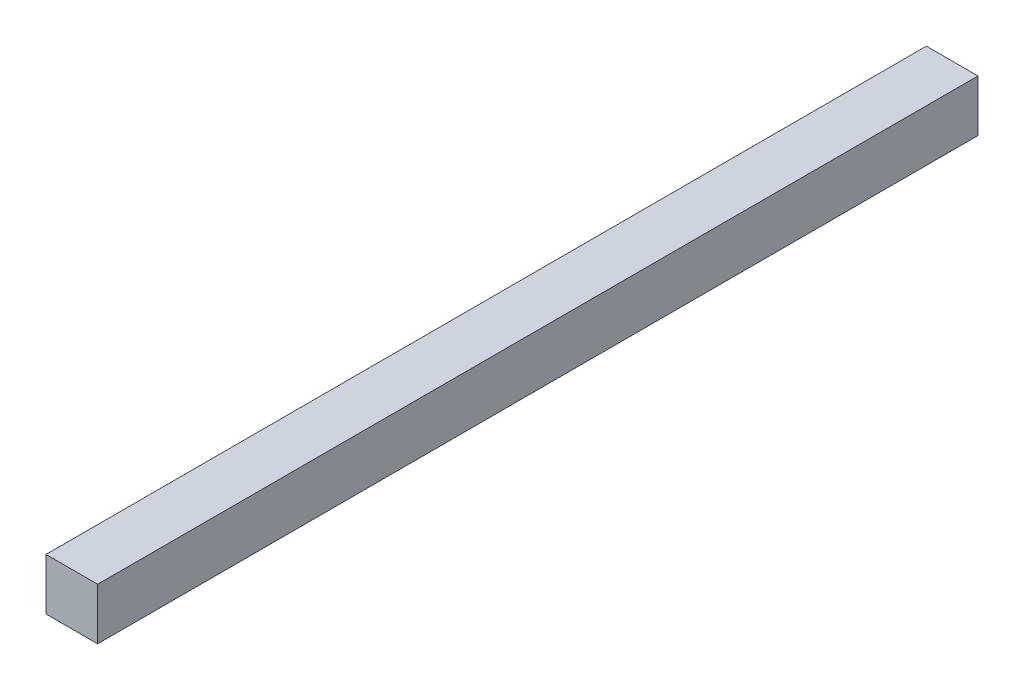
from build123d import *

# Parameters (mm, degrees)
SKETCH1_W           = 3.556
SKETCH1_H           = 3.556
BOSS_EXTRUDE1_DEPTH = 60.6425


with BuildPart() as part:
    # Sketch1 → Boss-Extrude1 (new body)
    with BuildSketch(Plane.XY):
        with Locations((1.778, -1.778)):
            Rectangle(SKETCH1_W, SKETCH1_H)
    extrude(amount=BOSS_EXTRUDE1_DEPTH)


solid = part.part
